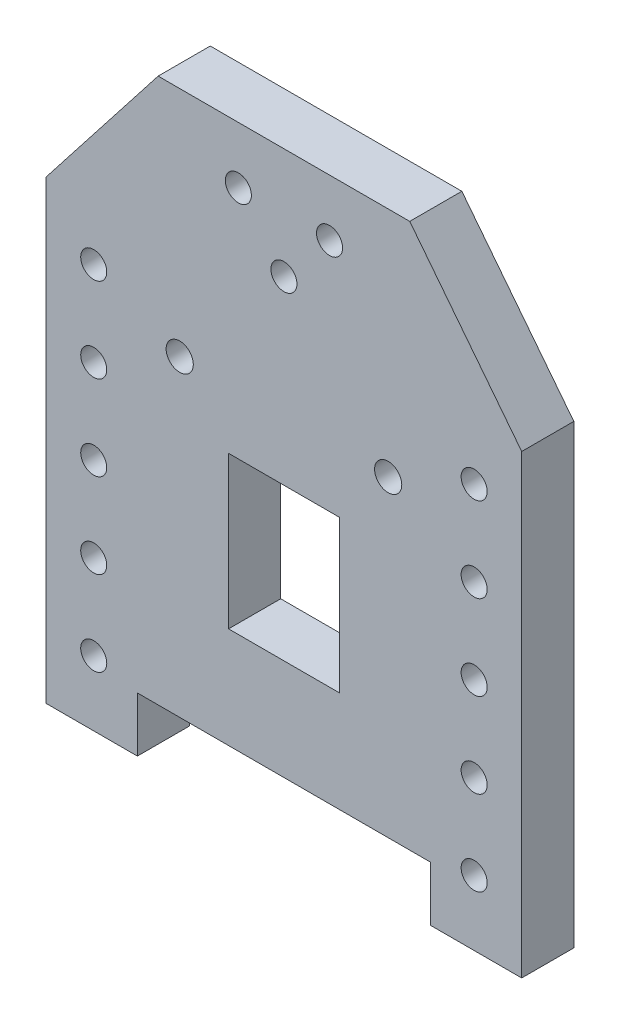
from build123d import *

# Parameters (mm, degrees)
ESBO_O1_R                = 2
ESBO_O1_R_2              = 2.086716092
ESBO_O1_R_3              = 2.086717953
RESSALTO_EXTRUS_O1_DEPTH = 8
ESBO_O2_R                = 2
CORTE_EXTRUS_O1_DEPTH    = 9


with BuildPart() as part:
    # Esboço1 → Ressalto-extrusão1 (new body)
    with BuildSketch(Plane.XY):
        Polygon((19.311716217, 92), (-19.311716217, 92), (-36.5, 70), (-36.5, 0), (-22.499999998, 0), (-22.499999998, 8.400000004), (22.499999998, 8.400000004), (22.499999998, 0), (36.5, 0), (36.5, 70), align=None)
        with Locations((0, 75)):
            Circle(ESBO_O1_R, mode=Mode.SUBTRACT)
        with Locations((-7, 83.3)):
            Circle(ESBO_O1_R, mode=Mode.SUBTRACT)
        with Locations((7, 83.3)):
            Circle(ESBO_O1_R, mode=Mode.SUBTRACT)
        with Locations((-29.2, 10)):
            Circle(ESBO_O1_R, mode=Mode.SUBTRACT)
        with Locations((29.2, 10)):
            Circle(ESBO_O1_R, mode=Mode.SUBTRACT)
        with Locations((-16, 56.354540575)):
            Circle(ESBO_O1_R_2, mode=Mode.SUBTRACT)
        with Locations((16, 56.354540575)):
            Circle(ESBO_O1_R_3, mode=Mode.SUBTRACT)
        Polygon((0, 47.257129716), (8.5, 47.257129716), (8.5, 23.917682695), (0, 23.917682695), (-8.5, 23.917682695), (-8.5, 47.257129716), align=None, mode=Mode.SUBTRACT)
    extrude(amount=RESSALTO_EXTRUS_O1_DEPTH)

    # Esboço2 → Corte-extrusão1 (cut, through all)
    with BuildSketch(Plane(origin=(0, 0, 0), x_dir=(-1, 0, 0), z_dir=(0, 0, -1))):
        with Locations((29.2, 23)):
            Circle(ESBO_O2_R)
        with Locations((29.2, 36)):
            Circle(ESBO_O2_R)
        with Locations((29.2, 49)):
            Circle(ESBO_O2_R)
        with Locations((29.2, 62)):
            Circle(ESBO_O2_R)
        with Locations((-29.2, 49)):
            Circle(ESBO_O2_R)
        with Locations((-29.2, 36)):
            Circle(ESBO_O2_R)
        with Locations((-29.2, 62)):
            Circle(ESBO_O2_R)
        with Locations((-29.2, 23)):
            Circle(ESBO_O2_R)
    extrude(amount=-CORTE_EXTRUS_O1_DEPTH, mode=Mode.SUBTRACT)


solid = part.part
